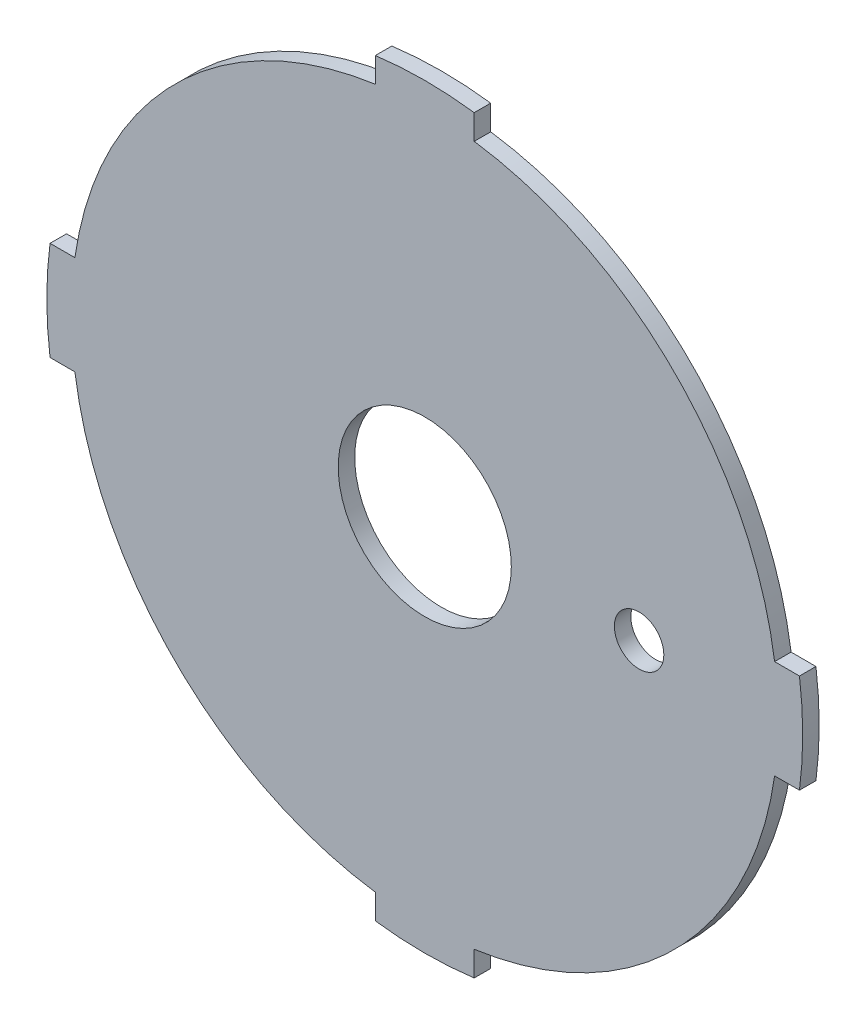
from build123d import *

# Parameters (mm, degrees)
SKETCH1_R           = 45.85
SKETCH1_R_2         = 10.5
BOSS_EXTRUDE1_DEPTH = 2
CUT_EXTRUDE1_REACH  = 4
SKETCH2_R           = 3
CUT_EXTRUDE2_REACH  = 4


with BuildPart() as part:
    # Sketch1 → Boss-Extrude1 (new body)
    with BuildSketch(Plane.XY):
        Circle(SKETCH1_R)
        Circle(SKETCH1_R_2, mode=Mode.SUBTRACT)
    extrude(amount=BOSS_EXTRUDE1_DEPTH)

    # Sketch2 → Cut-Extrude1 (cut, up to next)
    with BuildSketch(Plane(origin=(0, 0, 0), x_dir=(-1, 0, 0), z_dir=(0, 0, -1)), mode=Mode.PRIVATE) as cut_extrude1_sk1:
        with Locations((-26, 0)):
            Circle(SKETCH2_R)
    cut_extrude1_tool1 = extrude(cut_extrude1_sk1.sketch, amount=-CUT_EXTRUDE1_REACH, mode=Mode.PRIVATE) & part.part
    add(cut_extrude1_tool1.solids().sort_by_distance((26, 0, 0))[0], mode=Mode.SUBTRACT)

    # Sketch3 → Cut-Extrude2 (cut, up to next)
    with BuildSketch(Plane(origin=(0, 0, 0), x_dir=(-1, 0, 0), z_dir=(0, 0, -1)), mode=Mode.PRIVATE) as cut_extrude2_sk1:
        with BuildLine():
            Line((-6, 42.437949998), (-6, 45.455720212))
            ThreePointArc((-6, 45.455720212), (-32.420845917, 32.420845917), (-45.455720212, 6))
            Line((-45.455720212, 6), (-42.437949998, 6))
            ThreePointArc((-42.437949998, 6), (-30.306596642, 30.306596642), (-6, 42.437949998))
        make_face()
    cut_extrude2_tool1 = extrude(cut_extrude2_sk1.sketch, amount=-CUT_EXTRUDE2_REACH, mode=Mode.PRIVATE) & part.part
    add(cut_extrude2_tool1.solids().sort_by_distance((6.557988, 43.946835, 0))[0], mode=Mode.SUBTRACT)
    # Sketch3 → Cut-Extrude2 (cut, up to next)
    with BuildSketch(Plane(origin=(0, 0, 0), x_dir=(-1, 0, 0), z_dir=(0, 0, -1)), mode=Mode.PRIVATE) as cut_extrude2_sk2:
        with BuildLine():
            Line((42.437949998, 6), (45.455720212, 6))
            ThreePointArc((45.455720212, 6), (32.420845917, 32.420845917), (6, 45.455720212))
            Line((6, 45.455720212), (6, 42.437949998))
            ThreePointArc((6, 42.437949998), (30.306596642, 30.306596642), (42.437949998, 6))
        make_face()
    cut_extrude2_tool2 = extrude(cut_extrude2_sk2.sketch, amount=-CUT_EXTRUDE2_REACH, mode=Mode.PRIVATE) & part.part
    add(cut_extrude2_tool2.solids().sort_by_distance((-43.946835, 6.557988, 0))[0], mode=Mode.SUBTRACT)
    # Sketch3 → Cut-Extrude2 (cut, up to next)
    with BuildSketch(Plane(origin=(0, 0, 0), x_dir=(-1, 0, 0), z_dir=(0, 0, -1)), mode=Mode.PRIVATE) as cut_extrude2_sk3:
        with BuildLine():
            Line((6, -42.437949998), (6, -45.455720212))
            ThreePointArc((6, -45.455720212), (32.420845917, -32.420845917), (45.455720212, -6))
            Line((45.455720212, -6), (42.437949998, -6))
            ThreePointArc((42.437949998, -6), (30.306596642, -30.306596642), (6, -42.437949998))
        make_face()
    cut_extrude2_tool3 = extrude(cut_extrude2_sk3.sketch, amount=-CUT_EXTRUDE2_REACH, mode=Mode.PRIVATE) & part.part
    add(cut_extrude2_tool3.solids().sort_by_distance((-32.026289, -32.026289, 0))[0], mode=Mode.SUBTRACT)
    # Sketch3 → Cut-Extrude2 (cut, up to next)
    with BuildSketch(Plane(origin=(0, 0, 0), x_dir=(-1, 0, 0), z_dir=(0, 0, -1)), mode=Mode.PRIVATE) as cut_extrude2_sk4:
        with BuildLine():
            Line((-42.437949998, -6), (-45.455720212, -6))
            ThreePointArc((-45.455720212, -6), (-32.420845917, -32.420845917), (-6, -45.455720212))
            Line((-6, -45.455720212), (-6, -42.437949998))
            ThreePointArc((-6, -42.437949998), (-30.306596642, -30.306596642), (-42.437949998, -6))
        make_face()
    cut_extrude2_tool4 = extrude(cut_extrude2_sk4.sketch, amount=-CUT_EXTRUDE2_REACH, mode=Mode.PRIVATE) & part.part
    add(cut_extrude2_tool4.solids().sort_by_distance((6.557988, -43.946835, 0))[0], mode=Mode.SUBTRACT)


solid = part.part
